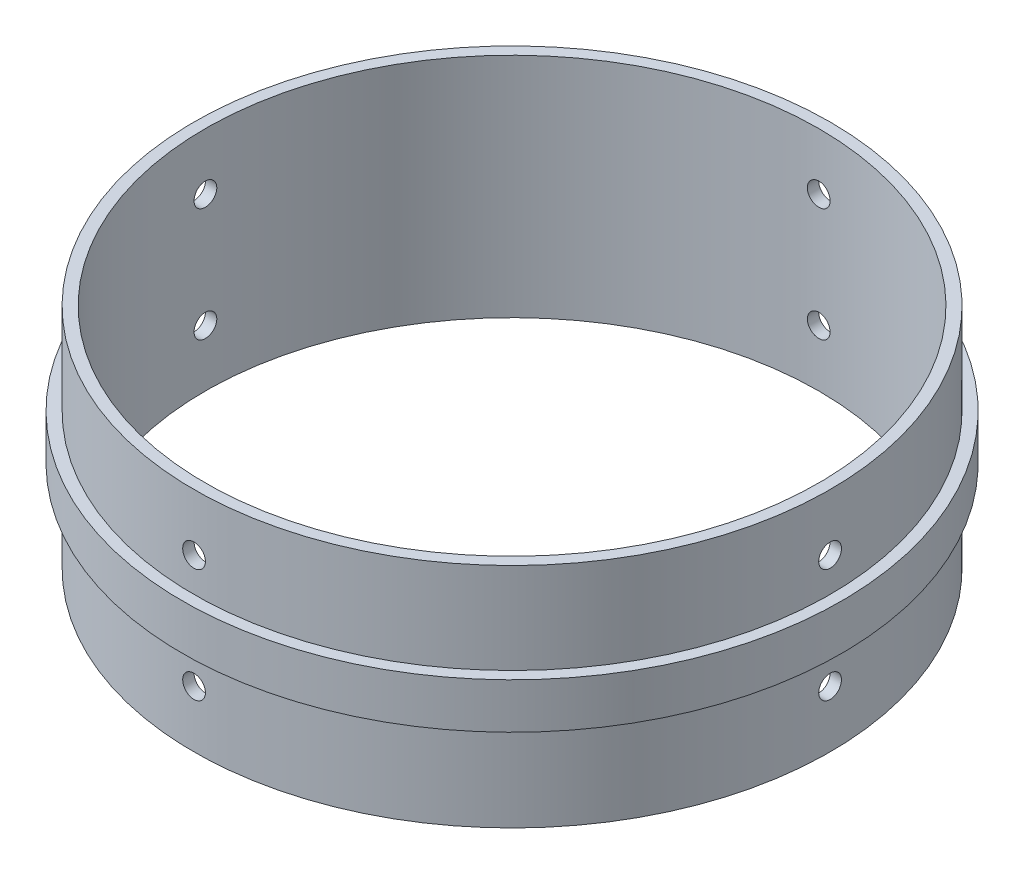
from build123d import *

# Parameters (mm, degrees)
SKETCH2_R               = 3.175
CUT_EXTRUDE1_DEPTH      = 93.075
CUT_EXTRUDE1_DEPTH_BACK = 93.075
SKETCH3_R               = 3.175
CUT_EXTRUDE2_DEPTH      = 93.075
CUT_EXTRUDE2_DEPTH_BACK = 93.075


with BuildPart() as part:
    # Sketch1 → Revolve1 (revolve)
    with BuildSketch(Plane.XY):
        Polygon((92.075, 25.4), (92.075, 38.1), (88.9, 38.1), (88.9, 63.5), (85.725, 63.5), (85.725, 0), (88.9, 0), (88.9, 25.4), align=None)
    revolve(axis=Axis((0, 0, 0), (0, 1, 0)))

    # Sketch2 → Cut-Extrude1 (cut, two sides)
    with BuildSketch(Plane.XY) as cut_extrude1_sk:
        with Locations((0, 47.625)):
            Circle(SKETCH2_R)
        with Locations((0, 15.875)):
            Circle(SKETCH2_R)
    extrude(amount=CUT_EXTRUDE1_DEPTH, mode=Mode.SUBTRACT)
    extrude(cut_extrude1_sk.sketch, amount=-CUT_EXTRUDE1_DEPTH_BACK, mode=Mode.SUBTRACT)

    # Sketch3 → Cut-Extrude2 (cut, two sides)
    with BuildSketch(Plane(origin=(0, 0, 0), x_dir=(0, 0, -1), z_dir=(1, 0, 0))) as cut_extrude2_sk:
        with Locations((0, 47.625)):
            Circle(SKETCH3_R)
        with Locations((0, 15.875)):
            Circle(SKETCH3_R)
    extrude(amount=CUT_EXTRUDE2_DEPTH, mode=Mode.SUBTRACT)
    extrude(cut_extrude2_sk.sketch, amount=-CUT_EXTRUDE2_DEPTH_BACK, mode=Mode.SUBTRACT)


solid = part.part
